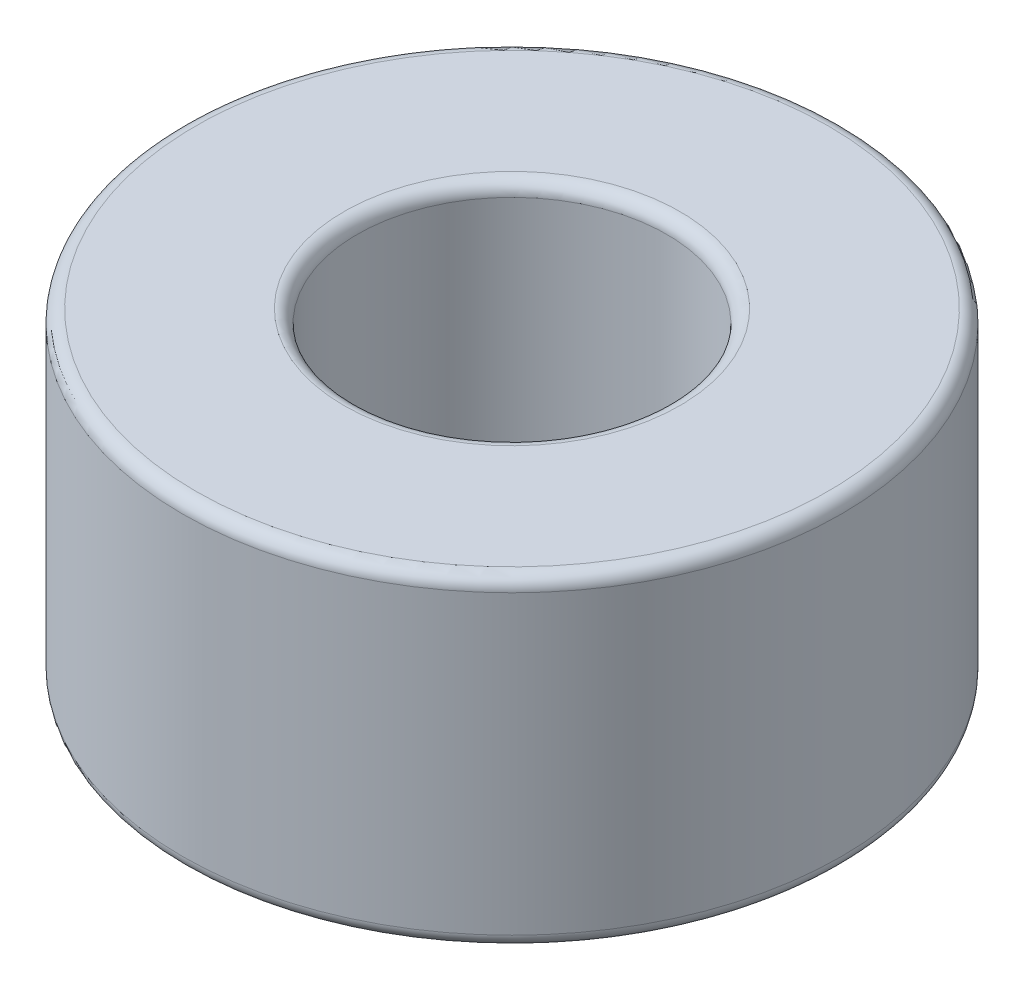
from build123d import *

# Parameters (mm, degrees)
SKETCH1_R           = 6.35
SKETCH1_R_2         = 2.9845
BOSS_EXTRUDE1_DEPTH = 6.223
FILLET1_R           = 0.254


with BuildPart() as part:
    # Sketch1 → Boss-Extrude1 (new body)
    with BuildSketch(Plane(origin=(0, 0, 0), x_dir=(1, 0, 0), z_dir=(0, 1, 0))):
        Circle(SKETCH1_R)
        Circle(SKETCH1_R_2, mode=Mode.SUBTRACT)
    extrude(amount=BOSS_EXTRUDE1_DEPTH)

    # Fillet1
    fillet1_edges = [part.edges().sort_by_distance(p)[0] for p in [
        (-6.35, 0, 0),
        (-6.35, 6.223, 0),
        (-2.9845, 0, 0),
        (-2.9845, 6.223, 0),
    ]]
    fillet(fillet1_edges, radius=FILLET1_R)


solid = part.part
